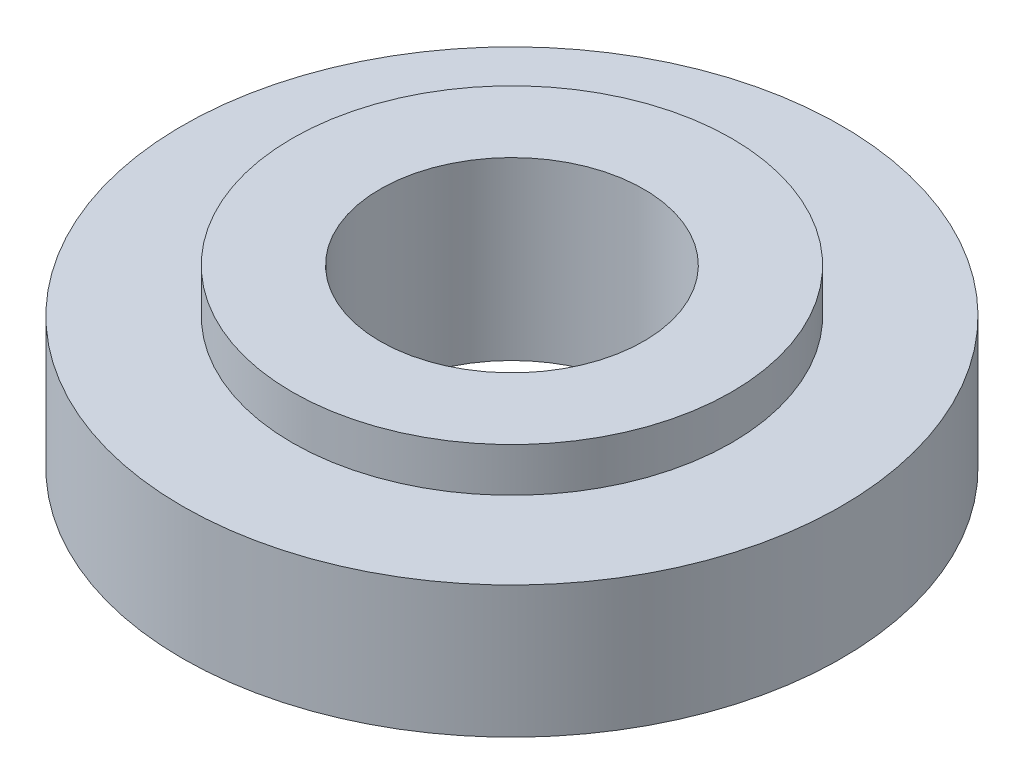
from build123d import *

# Parameters (mm, degrees)
SKETCH1_R           = 3.75
SKETCH1_R_2         = 1.5
BOSS_EXTRUDE1_DEPTH = 1.5
BOSS_EXTRUDE2_START = 0.5
SKETCH1_3_R         = 2.5
SKETCH1_3_R_2       = 1.5
BOSS_EXTRUDE2_DEPTH = 0.5
SCALE1_SCALE        = 1.667


with BuildPart() as part:
    # Sketch1 → Boss-Extrude1 (new body)
    with BuildSketch(Plane(origin=(0, 0, 0), x_dir=(1, 0, 0), z_dir=(0, 1, 0))):
        Circle(SKETCH1_R)
        Circle(SKETCH1_R_2, mode=Mode.SUBTRACT)
    extrude(amount=-BOSS_EXTRUDE1_DEPTH)

    # Sketch1_3 → Boss-Extrude2 (add)
    with BuildSketch(Plane(origin=(0, 0, 0), x_dir=(1, 0, 0), z_dir=(0, 1, 0)).offset(BOSS_EXTRUDE2_START)):
        Circle(SKETCH1_3_R)
        Circle(SKETCH1_3_R_2, mode=Mode.SUBTRACT)
    extrude(amount=-BOSS_EXTRUDE2_DEPTH)


with BuildPart() as part_1:
    # Scale1: scaled about (0, -0.648573693, 0)
    add(part.part.scale(SCALE1_SCALE).moved(Location((0, 0.432598653, 0))))


solid = part_1.part
